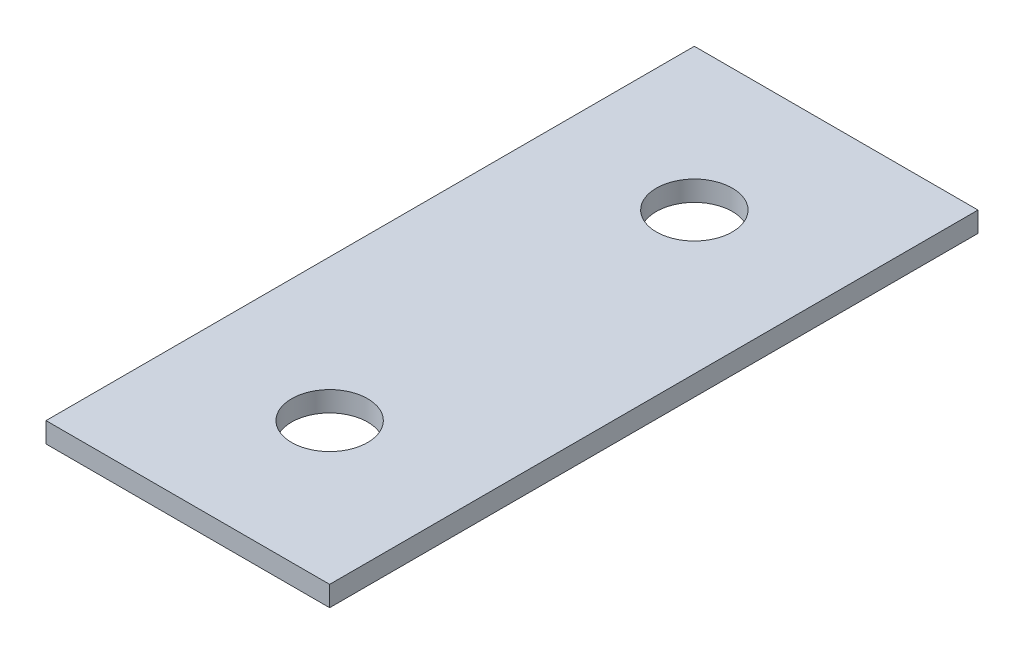
from build123d import *

# Parameters (mm, degrees)
SKETCH1_W           = 88.9
SKETCH1_H           = 203.2
SKETCH1_R           = 11.90625
BOSS_EXTRUDE1_DEPTH = 6.35


with BuildPart() as part:
    # Sketch1 → Boss-Extrude1 (new body)
    with BuildSketch(Plane(origin=(0, 0, 0), x_dir=(1, 0, 0), z_dir=(0, 1, 0))):
        with Locations((44.45, 101.6)):
            Rectangle(SKETCH1_W, SKETCH1_H)
        with Locations((44.45, 158.75)):
            Circle(SKETCH1_R, mode=Mode.SUBTRACT)
        with Locations((44.45, 44.45)):
            Circle(SKETCH1_R, mode=Mode.SUBTRACT)
    extrude(amount=BOSS_EXTRUDE1_DEPTH)


solid = part.part
